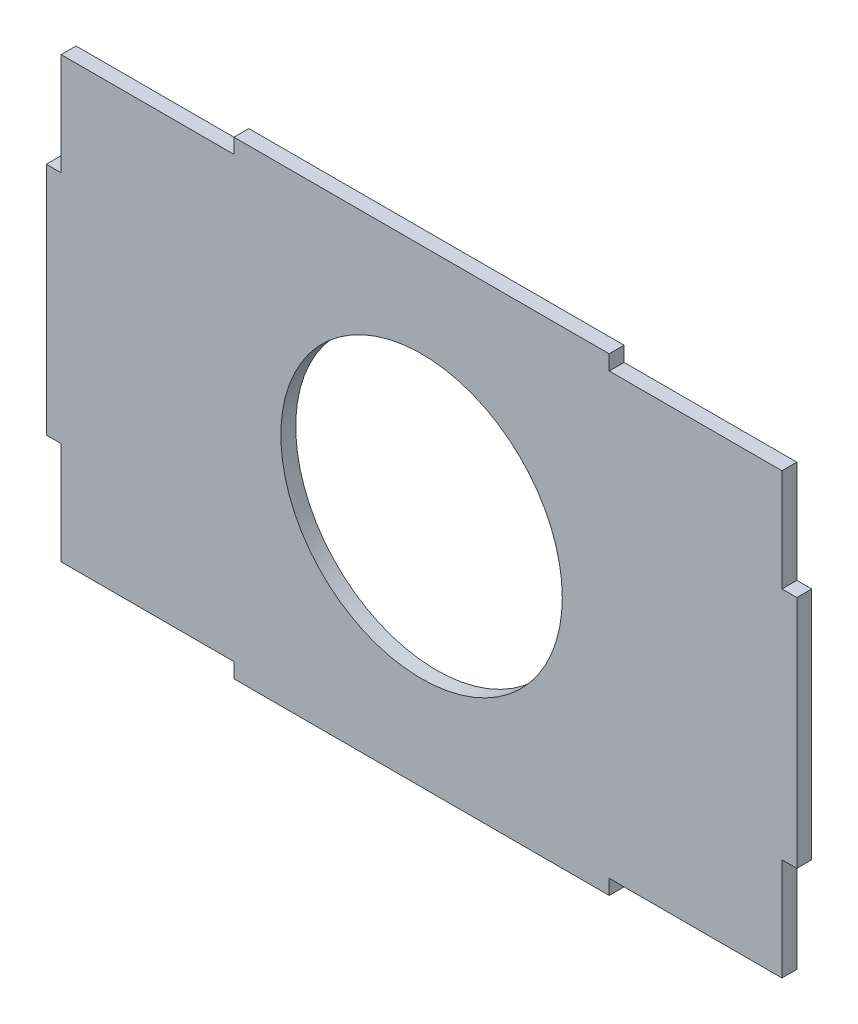
from build123d import *

# Parameters (mm, degrees)
BOSS_EXTRUDE2_DEPTH = 3.175
SKETCH2_R           = 30
CUT_EXTRUDE1_DEPTH  = 3.175


with BuildPart() as part:
    # Sketch1 → Boss-Extrude2 (new body)
    with BuildSketch(Plane.XY):
        Polygon((-40, 0), (40, 0), (40, 3.175), (76.825, 3.175), (76.825, 25), (80, 25), (80, 75), (76.825, 75), (76.825, 96.825), (40, 96.825), (40, 100), (-40, 100), (-40, 96.825), (-76.825, 96.825), (-76.825, 75), (-80, 75), (-80, 25), (-76.825, 25), (-76.825, 3.175), (-40, 3.175), align=None)
    extrude(amount=BOSS_EXTRUDE2_DEPTH)

    # Sketch2 → Cut-Extrude1 (cut)
    with BuildSketch(Plane.XY.offset(3.175)):
        with Locations((0, 50)):
            Circle(SKETCH2_R)
    extrude(amount=-CUT_EXTRUDE1_DEPTH, mode=Mode.SUBTRACT)


solid = part.part
